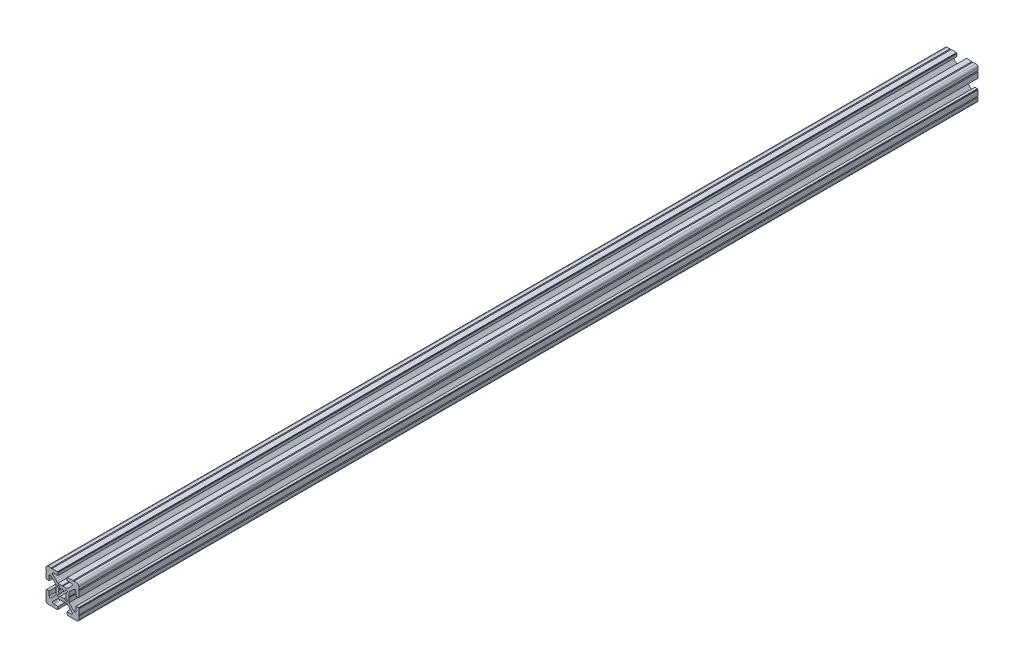
from build123d import *

# Parameters (mm, degrees)
BOSS_EXTRUDE1_DEPTH = 820


with BuildPart() as part:
    # Sketch1 → Boss-Extrude1 (new body)
    with BuildSketch(Plane(origin=(0, 0, -720), x_dir=(-1, 0, 0), z_dir=(0, 0, -1))):
        with BuildLine():
            Line((-14.999999999, 12.999999999), (-14.999999999, 10.499999999))
            Line((-14.999999999, 10.499999999), (-14.499999999, 9.999999999))
            Line((-14.499999999, 9.999999999), (-14.999999999, 9.5))
            Line((-14.999999999, 9.5), (-14.999999999, 4.5))
            Line((-14.999999999, 4.5), (-14.5, 4.5))
            Line((-14.5, 4.5), (-14.5, 4))
            Line((-14.5, 4), (-12.200000005, 4))
            Line((-12.200000005, 4), (-12.200000005, 7.999999995))
            ThreePointArc((-12.200000005, 7.999999995), (-11.582683434, 8.923879532), (-10.492893215, 8.70710678))
            Line((-10.492893215, 8.70710678), (-6, 4.214213564))
            Line((-6, 4.214213564), (-6, 0.312520903))
            Line((-6, 0.312520903), (-5.7, 0))
            Line((-5.7, 0), (-6, -0.312520901))
            Line((-6, -0.312520901), (-6, -4.214213564))
            Line((-6, -4.214213564), (-10.492893215, -8.70710678))
            ThreePointArc((-10.492893215, -8.70710678), (-11.582683434, -8.923879532), (-12.200000005, -7.999999995))
            Line((-12.200000005, -7.999999995), (-12.200000005, -4))
            Line((-12.200000005, -4), (-14.5, -4))
            Line((-14.5, -4), (-14.5, -4.5))
            Line((-14.5, -4.5), (-14.999999999, -4.5))
            Line((-14.999999999, -4.5), (-14.999999999, -9.500000003))
            Line((-14.999999999, -9.500000003), (-14.499999999, -10.000000002))
            Line((-14.499999999, -10.000000002), (-14.999999999, -10.500000001))
            Line((-14.999999999, -10.500000001), (-14.999999999, -13))
            ThreePointArc((-14.999999999, -13), (-14.414213561, -14.414213562), (-12.999999999, -15))
            Line((-12.999999999, -15), (-10.5, -15))
            Line((-10.5, -15), (-10.000000001, -14.500000001))
            Line((-10.000000001, -14.500000001), (-9.500000001, -15))
            Line((-9.500000001, -15), (-4.5, -15))
            Line((-4.5, -15), (-4.5, -14.5))
            Line((-4.5, -14.5), (-4, -14.5))
            Line((-4, -14.5), (-4, -12.200000005))
            Line((-4, -12.200000005), (-7.999999995, -12.200000005))
            ThreePointArc((-7.999999995, -12.200000005), (-8.923879532, -11.582683434), (-8.70710678, -10.492893215))
            Line((-8.70710678, -10.492893215), (-4.214213564, -6))
            Line((-4.214213564, -6), (-0.312520903, -6))
            Line((-0.312520903, -6), (0, -5.7))
            Line((0, -5.7), (0.312520901, -6))
            Line((0.312520901, -6), (4.214213564, -6))
            Line((4.214213564, -6), (8.70710678, -10.492893215))
            ThreePointArc((8.70710678, -10.492893215), (8.923879532, -11.582683434), (7.999999995, -12.200000005))
            Line((7.999999995, -12.200000005), (4, -12.200000005))
            Line((4, -12.200000005), (4, -14.5))
            Line((4, -14.5), (4.5, -14.5))
            Line((4.5, -14.5), (4.5, -15))
            Line((4.5, -15), (9.500000001, -15))
            Line((9.500000001, -15), (9.989897949, -14.5))
            Line((9.989897949, -14.5), (10.489897949, -15))
            Line((10.489897949, -15), (13, -15))
            ThreePointArc((13, -15), (14.414213562, -14.414213562), (15, -13))
            Line((15, -13), (15, -10.5))
            Line((15, -10.5), (14.500000001, -10.000000001))
            Line((14.500000001, -10.000000001), (15, -9.500000001))
            Line((15, -9.500000001), (15, -4.5))
            Line((15, -4.5), (14.5, -4.5))
            Line((14.5, -4.5), (14.5, -4))
            Line((14.5, -4), (12.200000005, -4))
            Line((12.200000005, -4), (12.200000005, -7.999999995))
            ThreePointArc((12.200000005, -7.999999995), (11.582683434, -8.923879532), (10.492893215, -8.70710678))
            Line((10.492893215, -8.70710678), (6, -4.214213564))
            Line((6, -4.214213564), (6, -0.312520903))
            Line((6, -0.312520903), (5.7, 0))
            Line((5.7, 0), (6, 0.312520901))
            Line((6, 0.312520901), (6, 4.214213564))
            Line((6, 4.214213564), (10.492893215, 8.707106779))
            ThreePointArc((10.492893215, 8.707106779), (11.582683434, 8.923879532), (12.200000005, 7.999999994))
            Line((12.200000005, 7.999999994), (12.200000005, 4))
            Line((12.200000005, 4), (14.5, 4))
            Line((14.5, 4), (14.5, 4.5))
            Line((14.5, 4.5), (15, 4.5))
            Line((15, 4.5), (15, 9.500000001))
            Line((15, 9.500000001), (14.500000001, 10.000000001))
            Line((14.500000001, 10.000000001), (15, 10.5))
            Line((15, 10.5), (15, 12.999999999))
            ThreePointArc((15, 12.999999999), (14.414213562, 14.414213561), (13, 14.999999999))
            Line((13, 14.999999999), (10.500000001, 14.999999999))
            Line((10.500000001, 14.999999999), (10.000000002, 14.499999999))
            Line((10.000000002, 14.499999999), (9.500000002, 14.999999999))
            Line((9.500000002, 14.999999999), (4.5, 14.999999999))
            Line((4.5, 14.999999999), (4.5, 14.5))
            Line((4.5, 14.5), (4, 14.5))
            Line((4, 14.5), (4, 12.200000005))
            Line((4, 12.200000005), (7.999999995, 12.200000005))
            ThreePointArc((7.999999995, 12.200000005), (8.923879532, 11.582683434), (8.70710678, 10.492893215))
            Line((8.70710678, 10.492893215), (4.214213564, 6))
            Line((4.214213564, 6), (0.312520903, 6))
            Line((0.312520903, 6), (0, 5.7))
            Line((0, 5.7), (-0.312520901, 6))
            Line((-0.312520901, 6), (-4.214213564, 6))
            Line((-4.214213564, 6), (-8.707106779, 10.492893215))
            ThreePointArc((-8.707106779, 10.492893215), (-8.923879532, 11.582683434), (-7.999999994, 12.200000005))
            Line((-7.999999994, 12.200000005), (-4, 12.200000005))
            Line((-4, 12.200000005), (-4, 14.5))
            Line((-4, 14.5), (-4.5, 14.5))
            Line((-4.5, 14.5), (-4.5, 14.999999999))
            Line((-4.5, 14.999999999), (-9.5, 14.999999999))
            Line((-9.5, 14.999999999), (-9.999999999, 14.499999999))
            Line((-9.999999999, 14.499999999), (-10.499999999, 14.999999999))
            Line((-10.499999999, 14.999999999), (-12.999999999, 14.999999999))
            ThreePointArc((-12.999999999, 14.999999999), (-14.414213561, 14.414213561), (-14.999999999, 12.999999999))
        make_face()
        with BuildLine():
            Line((4.808326112, 3.676955262), (2.902349714, 1.770978864))
            ThreePointArc((2.902349714, 1.770978864), (3.4, 0), (2.902349714, -1.770978864))
            Line((2.902349714, -1.770978864), (4.808326112, -3.676955262))
            Line((4.808326112, -3.676955262), (3.676955262, -4.808326112))
            Line((3.676955262, -4.808326112), (1.770978864, -2.902349714))
            ThreePointArc((1.770978864, -2.902349714), (0, -3.4), (-1.770978864, -2.902349714))
            Line((-1.770978864, -2.902349714), (-3.676955262, -4.808326112))
            Line((-3.676955262, -4.808326112), (-4.808326112, -3.676955262))
            Line((-4.808326112, -3.676955262), (-2.902349714, -1.770978864))
            ThreePointArc((-2.902349714, -1.770978864), (-3.4, 0), (-2.902349714, 1.770978864))
            Line((-2.902349714, 1.770978864), (-4.808326112, 3.676955262))
            Line((-4.808326112, 3.676955262), (-3.676955262, 4.808326112))
            Line((-3.676955262, 4.808326112), (-1.770978864, 2.902349714))
            ThreePointArc((-1.770978864, 2.902349714), (0, 3.4), (1.770978864, 2.902349714))
            Line((1.770978864, 2.902349714), (3.676955262, 4.808326112))
            Line((3.676955262, 4.808326112), (4.808326112, 3.676955262))
        make_face(mode=Mode.SUBTRACT)
    extrude(amount=-BOSS_EXTRUDE1_DEPTH)


solid = part.part
